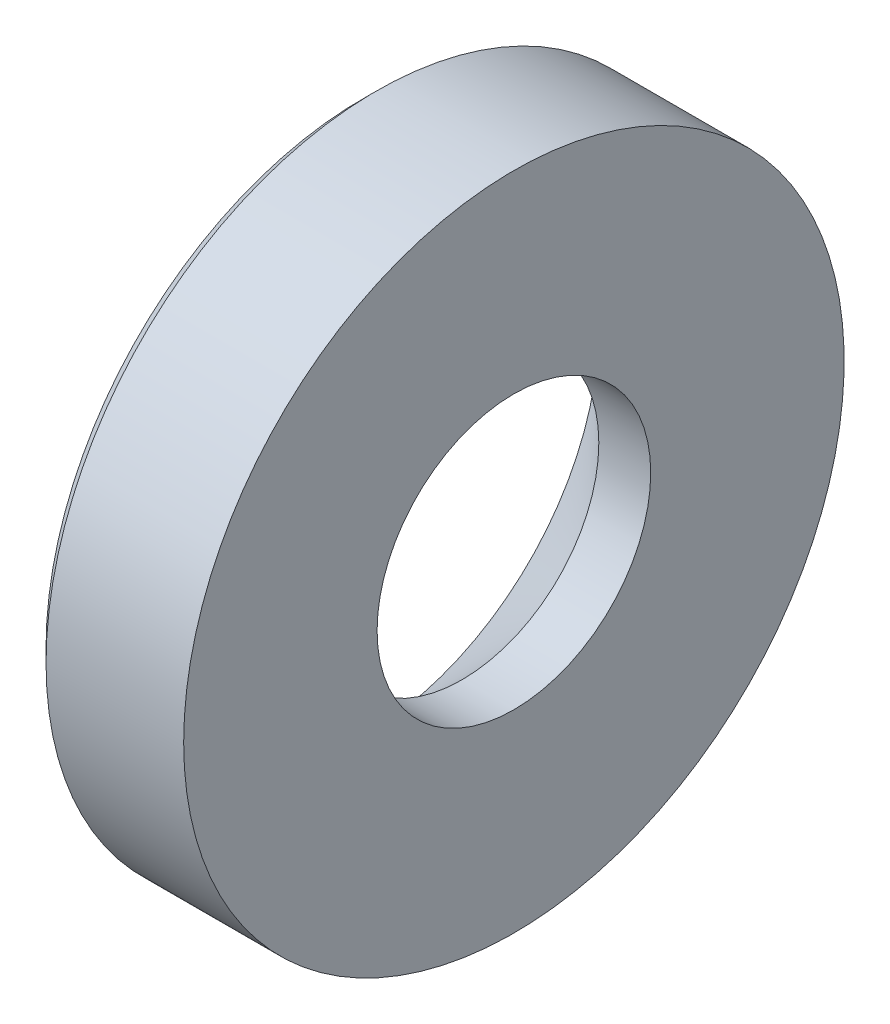
from build123d import *


with BuildPart() as part:
    # Sketch1 → Revolve1 (revolve)
    with BuildSketch(Plane.XY):
        Polygon((37.224937155, 7.25), (34.474937155, 7.25), (29.224937155, 12.5), (29.224937155, 16.792893219), (29.932043936, 17.5), (37.224937155, 17.5), (37.224937155, 9.702159296), align=None)
    revolve(axis=Axis((-58.75390838, 0, 0), (1, 0, 0)))


solid = part.part
